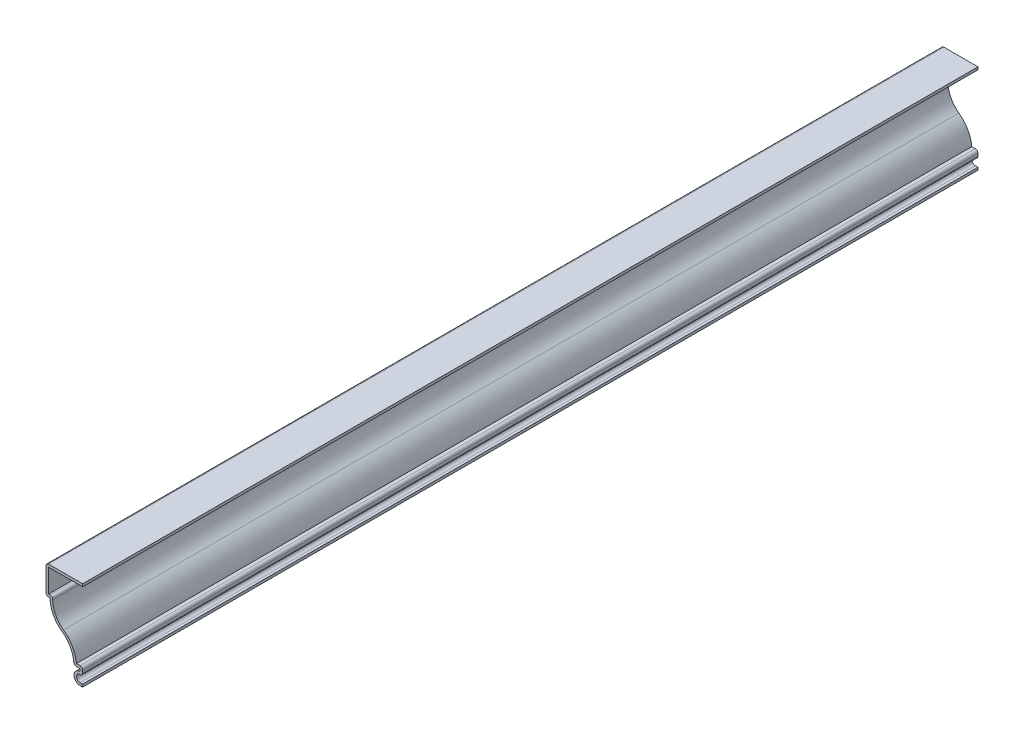
from build123d import *

# Parameters (mm, degrees)
EXTRUDE_THIN1_DEPTH = 349.25
FILLET1_R           = 1.016


with BuildPart() as part:
    # Sketch1 → Extrude-Thin1 (new body)
    with BuildSketch(Plane.XY):
        with BuildLine():
            Line((0, 34.925), (-14.2875, 34.925))
            Line((-14.2875, 34.925), (-14.2875, 23.8125))
            Line((-14.2875, 23.8125), (-12.7, 23.8125))
            ThreePointArc((-12.7, 23.8125), (-11.46897023, 18.728780658), (-8.048625, 14.771398298))
            ThreePointArc((-8.048625, 14.771398298), (-4.62827977, 10.814015938), (-3.39725, 5.730296596))
            Line((-3.39725, 5.730296596), (-1.016, 5.730296596))
            Line((-1.016, 5.730296596), (-1.016, 4.7625))
            ThreePointArc((-1.016, 4.7625), (-3.39725, 2.38125), (-1.016, 0))
            Line((-1.016, 0), (0, 0))
            Line((0, 0), (0, 1.016))
            Line((0, 1.016), (-1.016, 1.016))
            ThreePointArc((-1.016, 1.016), (-2.26278514, 2.93751826), (0, 3.29319932))
            Line((0, 3.29319932), (0, 6.746296596))
            Line((0, 6.746296596), (-2.423879893, 6.746296596))
            ThreePointArc((-2.423879893, 6.746296596), (-3.966915161, 11.726057249), (-7.457893571, 15.598013311))
            ThreePointArc((-7.457893571, 15.598013311), (-10.786815308, 19.651741643), (-11.632750432, 24.8285))
            Line((-11.632750432, 24.8285), (-13.2715, 24.8285))
            Line((-13.2715, 24.8285), (-13.2715, 33.909))
            Line((-13.2715, 33.909), (0, 33.909))
            Line((0, 33.909), (0, 34.925))
        make_face()
    extrude(amount=-EXTRUDE_THIN1_DEPTH)

    # Fillet1
    fillet1_edges = [part.edges().sort_by_distance(p)[0] for p in [
        (-11.632750432, 24.8285, -174.625),
        (0, 6.746296596, -174.625),
        (0, 3.29319932, -174.625),
        (-3.39725, 5.730296596, -174.625),
        (-14.2875, 23.8125, -174.625),
        (-14.2875, 34.925, -174.625),
    ]]
    fillet(fillet1_edges, radius=FILLET1_R)


solid = part.part
